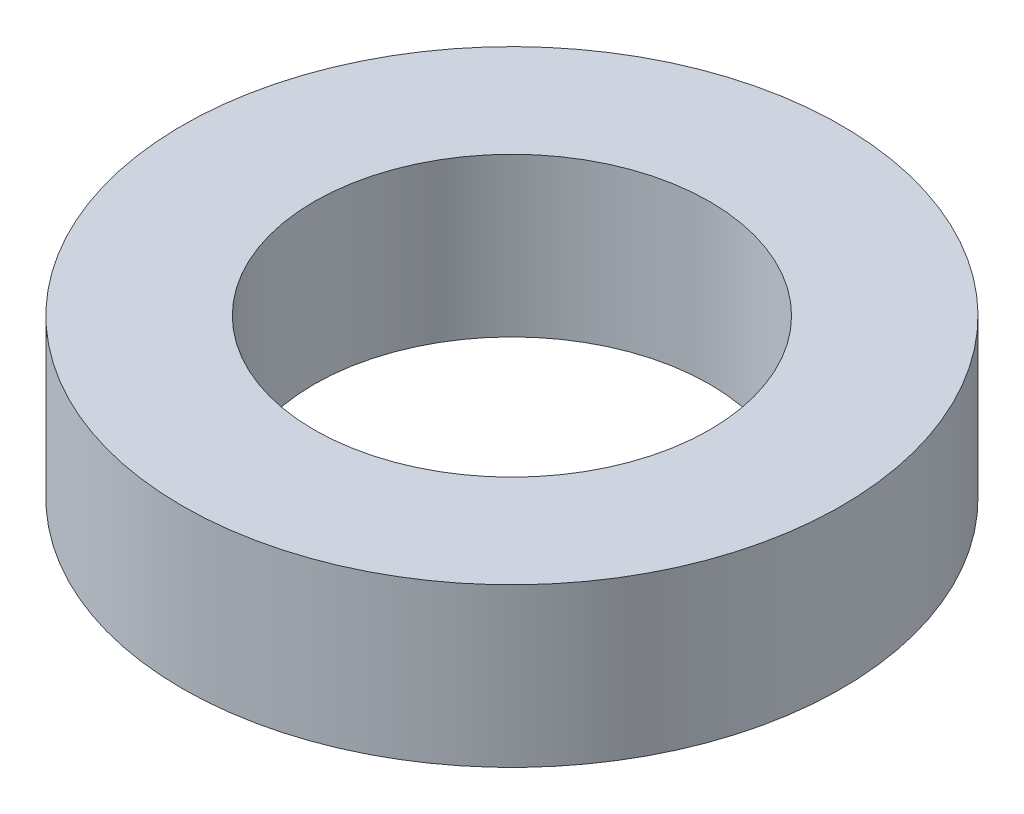
from build123d import *

# Parameters (mm, degrees)
SKETCH1_R           = 7.9375
SKETCH1_R_2         = 4.7625
BOSS_EXTRUDE1_DEPTH = 3.81


with BuildPart() as part:
    # Sketch1 → Boss-Extrude1 (new body)
    with BuildSketch(Plane(origin=(0, 0, 0), x_dir=(1, 0, 0), z_dir=(0, 1, 0))):
        Circle(SKETCH1_R)
        Circle(SKETCH1_R_2, mode=Mode.SUBTRACT)
    extrude(amount=BOSS_EXTRUDE1_DEPTH)


solid = part.part
